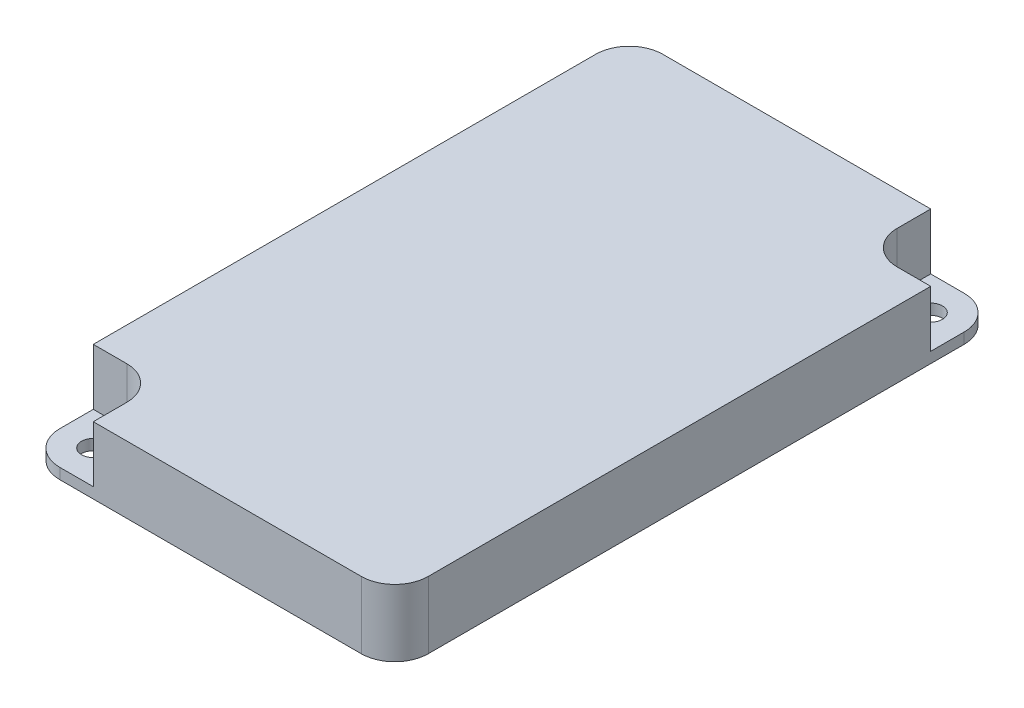
from build123d import *

# Parameters (mm, degrees)
SKETCH_1_R          = 1.75
EXTRUDE_1_DEPTH     = 10
SKETCH_2_R          = 1.75
CUT_EXTRUDE_2_DEPTH = 8.4


with BuildPart() as part:
    # 草图1 → 凸台-拉伸1 (new body)
    with BuildSketch(Plane(origin=(0, 0, 0), x_dir=(1, 0, 0), z_dir=(0, 1, 0))):
        with BuildLine():
            Line((-22.5, -45), (22.5, -45))
            ThreePointArc((22.5, -45), (26.035533906, -43.535533906), (27.5, -40))
            Line((27.5, -40), (27.5, 40))
            ThreePointArc((27.5, 40), (26.035533906, 43.535533906), (22.5, 45))
            Line((22.5, 45), (-22.5, 45))
            ThreePointArc((-22.5, 45), (-26.035533906, 43.535533906), (-27.5, 40))
            Line((-27.5, 40), (-27.5, -40))
            ThreePointArc((-27.5, -40), (-26.035533906, -43.535533906), (-22.5, -45))
        make_face()
        with Locations((-22.5, -40)):
            Circle(SKETCH_1_R, mode=Mode.SUBTRACT)
        with Locations((22.5, 40)):
            Circle(SKETCH_1_R, mode=Mode.SUBTRACT)
    extrude(amount=EXTRUDE_1_DEPTH)

    # 草图2 → 切除-拉伸2 (cut)
    with BuildSketch(Plane(origin=(0, 10, 0), x_dir=(1, 0, 0), z_dir=(0, 1, 0))):
        with BuildLine():
            Line((-27.5, -35), (-27.5, -40))
            ThreePointArc((-27.5, -40), (-26.035533906, -43.535533906), (-22.5, -45))
            Line((-22.5, -45), (-17.5, -45))
            Line((-17.5, -45), (-17.5, -40))
            ThreePointArc((-17.5, -40), (-18.964466094, -36.464466094), (-22.5, -35))
            Line((-22.5, -35), (-27.5, -35))
        make_face()
        with Locations((-22.5, -40)):
            Circle(SKETCH_2_R, mode=Mode.SUBTRACT)
        with BuildLine():
            Line((22.5, 45), (17.5, 45))
            Line((17.5, 45), (17.5, 40))
            ThreePointArc((17.5, 40), (18.964466094, 36.464466094), (22.5, 35))
            Line((22.5, 35), (27.5, 35))
            Line((27.5, 35), (27.5, 40))
            ThreePointArc((27.5, 40), (26.035533906, 43.535533906), (22.5, 45))
        make_face()
        with Locations((22.5, 40)):
            Circle(SKETCH_2_R, mode=Mode.SUBTRACT)
    extrude(amount=-CUT_EXTRUDE_2_DEPTH, mode=Mode.SUBTRACT)


solid = part.part
